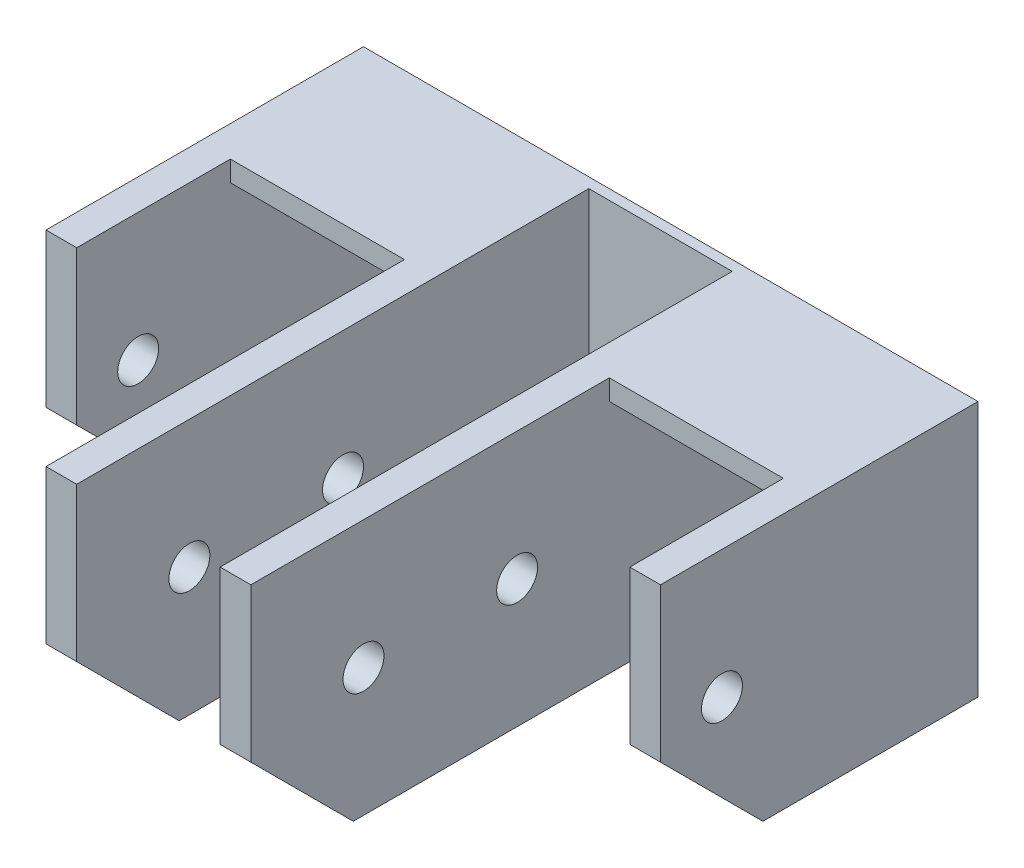
from build123d import *

# Parameters (mm, degrees)
SZKIC1_W                    = 60
SZKIC1_H                    = 25
DODANIE_WYCI_GNI_CIE1_DEPTH = 1
DODANIE_WYCI_GNI_CIE2_DEPTH = 50
SZKIC4_R                    = 2
WYTNIJ_WYCI_GNI_CIE1_DEPTH  = 61
SZKIC5_W                    = 17
SZKIC5_H                    = 2
WYTNIJ_WYCI_GNI_CIE2_DEPTH  = 35
SZKIC6_W                    = 20
SZKIC6_H                    = 25
WYTNIJ_WYCI_GNI_CIE3_DEPTH  = 3
SZKIC7_W                    = 20
SZKIC7_H                    = 25
WYTNIJ_WYCI_GNI_CIE4_DEPTH  = 3
SFAZOWANIE1_SIZE            = 10
SZKIC8_R                    = 2.5
WYTNIJ_WYCI_GNI_CIE5_DEPTH  = 3
SZKIC9_W                    = 14
SZKIC9_H                    = 2
WYTNIJ_WYCI_GNI_CIE6_DEPTH  = 50


with BuildPart() as part:
    # Szkic1 → Dodanie-wyciągnięcie1 (new body)
    with BuildSketch(Plane.XY):
        with Locations((30, 12.5)):
            Rectangle(SZKIC1_W, SZKIC1_H)
    extrude(amount=DODANIE_WYCI_GNI_CIE1_DEPTH)

    # Szkic3 → Dodanie-wyciągnięcie2 (add)
    with BuildSketch(Plane.XY.offset(1)):
        Polygon((0, 0), (0, 25), (60, 25), (60, 0), (57, 0), (57, 23), (40, 23), (40, 0), (37, 0), (37, 23), (23, 23), (23, 0), (20, 0), (20, 23), (3, 23), (3, 0), align=None)
    extrude(amount=DODANIE_WYCI_GNI_CIE2_DEPTH)

    # Szkic4 → Wytnij-wyciągnięcie1 (cut, through all)
    with BuildSketch(Plane.ZY):
        with Locations((25, 12.5)):
            Circle(SZKIC4_R)
        with Locations((40, 12.5)):
            Circle(SZKIC4_R)
    extrude(amount=-WYTNIJ_WYCI_GNI_CIE1_DEPTH, mode=Mode.SUBTRACT)

    # Szkic5 → Wytnij-wyciągnięcie2 (cut)
    with BuildSketch(Plane.XY.offset(51)):
        with Locations((48.5, 24)):
            Rectangle(SZKIC5_W, SZKIC5_H)
        with Locations((11.5, 24)):
            Rectangle(SZKIC5_W, SZKIC5_H)
    extrude(amount=-WYTNIJ_WYCI_GNI_CIE2_DEPTH, mode=Mode.SUBTRACT)

    # Szkic6 → Wytnij-wyciągnięcie3 (cut)
    with BuildSketch(Plane.ZY):
        with Locations((41, 12.5)):
            Rectangle(SZKIC6_W, SZKIC6_H)
    extrude(amount=-WYTNIJ_WYCI_GNI_CIE3_DEPTH, mode=Mode.SUBTRACT)

    # Szkic7 → Wytnij-wyciągnięcie4 (cut)
    with BuildSketch(Plane(origin=(60, 0, 0), x_dir=(0, 0, -1), z_dir=(1, 0, 0))):
        with Locations((-41, 12.5)):
            Rectangle(SZKIC7_W, SZKIC7_H)
    extrude(amount=-WYTNIJ_WYCI_GNI_CIE4_DEPTH, mode=Mode.SUBTRACT)

    # Sfazowanie1
    sfazowanie1_edges = [part.edges().sort_by_distance(p)[0] for p in [
        (1.5, 0, 31),
        (58.5, 0, 31),
        (21.5, 0, 51),
        (38.5, 0, 51),
    ]]
    chamfer(sfazowanie1_edges, length=SFAZOWANIE1_SIZE)

    # Szkic8 → Wytnij-wyciągnięcie5 (cut)
    with BuildSketch(Plane.XY.offset(1)):
        with Locations((11.5, 11.5)):
            Circle(SZKIC8_R)
        with Locations((48.5, 11.5)):
            Circle(SZKIC8_R)
    extrude(amount=-WYTNIJ_WYCI_GNI_CIE5_DEPTH, mode=Mode.SUBTRACT)

    # Szkic9 → Wytnij-wyciągnięcie6 (cut)
    with BuildSketch(Plane.XY.offset(51)):
        with Locations((30, 24)):
            Rectangle(SZKIC9_W, SZKIC9_H)
    extrude(amount=-WYTNIJ_WYCI_GNI_CIE6_DEPTH, mode=Mode.SUBTRACT)


solid = part.part
